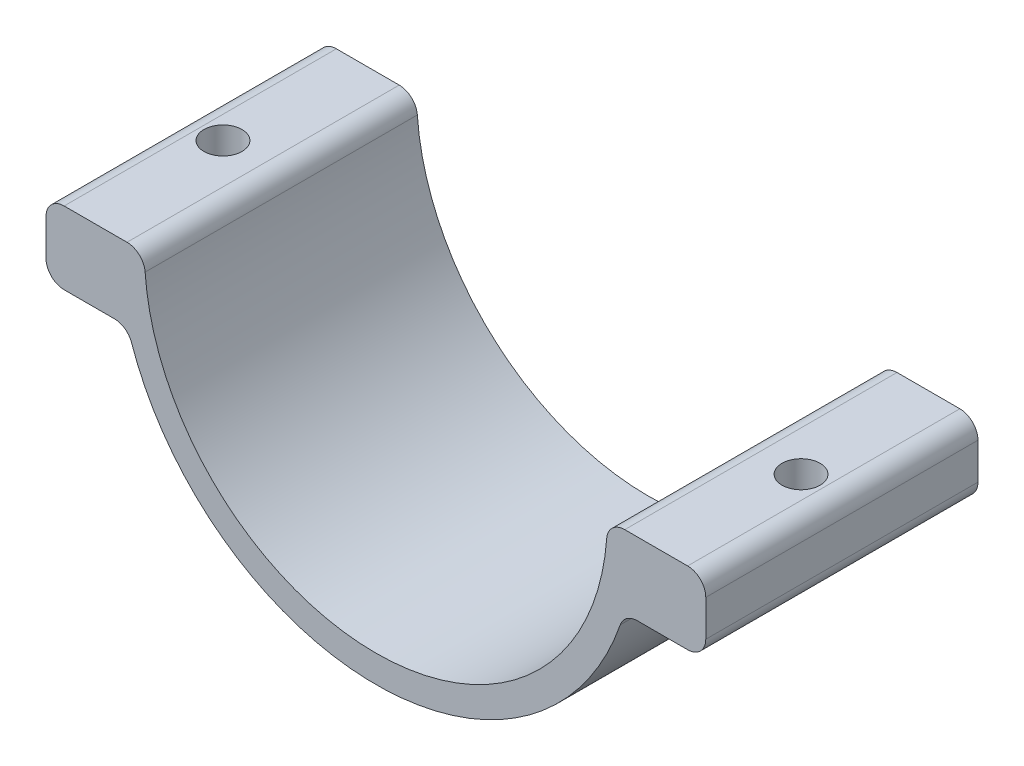
from build123d import *

# Parameters (mm, degrees)
BOSS_EXTRUDE1_DEPTH = 30
SKETCH5_R           = 2.1
CUT_EXTRUDE1_DEPTH  = 5
SKETCH6_R           = 1.65
CUT_EXTRUDE2_DEPTH  = 29.5
FILLET1_R           = 2


with BuildPart() as part:
    # Sketch3 → Boss-Extrude1 (new body)
    with BuildSketch(Plane.XY):
        with BuildLine():
            Line((-25.5, 0), (-36.354158733, 0))
            Line((-36.354158733, 0), (-36.354158733, -8))
            Line((-36.354158733, -8), (-27.354158733, -8))
            ThreePointArc((-27.354158733, -8), (0, -28.5), (27.354158733, -8))
            Line((27.354158733, -8), (36.354158733, -8))
            Line((36.354158733, -8), (36.354158733, 0))
            Line((36.354158733, 0), (25.5, 0))
            ThreePointArc((25.5, 0), (0, -25.5), (-25.5, 0))
        make_face()
    extrude(amount=BOSS_EXTRUDE1_DEPTH)

    # Sketch5 → Cut-Extrude1 (cut)
    with BuildSketch(Plane.XZ):
        with Locations((31.854158733, 15)):
            Circle(SKETCH5_R)
    cut_extrude1 = extrude(amount=CUT_EXTRUDE1_DEPTH, mode=Mode.SUBTRACT)

    # Sketch6 → Cut-Extrude2 (cut, through all)
    with BuildSketch(Plane(origin=(0, 0, 0), x_dir=(1, 0, 0), z_dir=(0, 1, 0))):
        with Locations((31.854158733, -15)):
            Circle(SKETCH6_R)
    cut_extrude2 = extrude(amount=-CUT_EXTRUDE2_DEPTH, mode=Mode.SUBTRACT)

    # Mirror1: Cut-Extrude1, Cut-Extrude2 across plane
    add(cut_extrude1.mirror(Plane(origin=(0, 0, 0), x_dir=(0, 0, 1), z_dir=(1, 0, 0))), mode=Mode.SUBTRACT)
    add(cut_extrude2.mirror(Plane(origin=(0, 0, 0), x_dir=(0, 0, 1), z_dir=(1, 0, 0))), mode=Mode.SUBTRACT)

    # Fillet1
    fillet1_edges = [part.edges().sort_by_distance(p)[0] for p in [
        (-36.354158733, 0, 15),
        (-25.5, 0, 15),
        (25.5, 0, 15),
        (36.354158733, 0, 15),
        (36.354158733, -8, 15),
        (27.354158733, -8, 15),
        (-27.354158733, -8, 15),
        (-36.354158733, -8, 15),
    ]]
    fillet(fillet1_edges, radius=FILLET1_R)


solid = part.part
